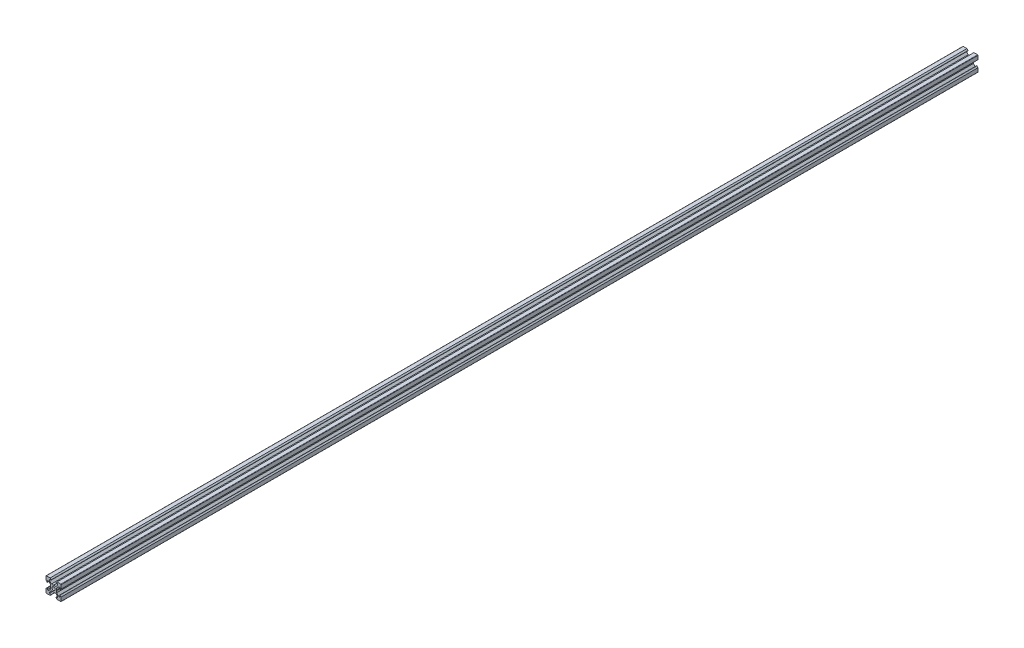
from build123d import *

# Parameters (mm, degrees)
SKETCH1_R           = 2.1
BOSS_EXTRUDE1_DEPTH = 1210


with BuildPart() as part:
    # Sketch1 → Boss-Extrude1 (new body)
    with BuildSketch(Plane.XY):
        with BuildLine():
            Line((4.58, -10), (9.5, -10))
            ThreePointArc((9.5, -10), (9.853553391, -9.853553391), (10, -9.5))
            Line((10, -9.5), (10, -4.58))
            Line((10, -4.58), (8.545, -3.125))
            Line((8.545, -3.125), (8.2, -3.125))
            Line((8.2, -3.125), (8.2, -5.5))
            Line((8.2, -5.5), (6.560660172, -5.5))
            Line((6.560660172, -5.5), (3.9, -2.839339828))
            Line((3.9, -2.839339828), (3.9, -0.21))
            Line((3.9, -0.21), (3.69, 0))
            Line((3.69, 0), (3.9, 0.21))
            Line((3.9, 0.21), (3.9, 2.839339828))
            Line((3.9, 2.839339828), (6.560660172, 5.5))
            Line((6.560660172, 5.5), (8.2, 5.5))
            Line((8.2, 5.5), (8.2, 3.125))
            Line((8.2, 3.125), (8.545, 3.125))
            Line((8.545, 3.125), (10, 4.58))
            Line((10, 4.58), (10, 9.5))
            ThreePointArc((10, 9.5), (9.853553391, 9.853553391), (9.5, 10))
            Line((9.5, 10), (4.58, 10))
            Line((4.58, 10), (3.125, 8.545))
            Line((3.125, 8.545), (3.125, 8.2))
            Line((3.125, 8.2), (5.5, 8.2))
            Line((5.5, 8.2), (5.5, 6.560660172))
            Line((5.5, 6.560660172), (2.839339828, 3.9))
            Line((2.839339828, 3.9), (0.21, 3.9))
            Line((0.21, 3.9), (0, 3.69))
            Line((0, 3.69), (-0.21, 3.9))
            Line((-0.21, 3.9), (-2.839339828, 3.9))
            Line((-2.839339828, 3.9), (-5.5, 6.560660172))
            Line((-5.5, 6.560660172), (-5.5, 8.2))
            Line((-5.5, 8.2), (-3.125, 8.2))
            Line((-3.125, 8.2), (-3.125, 8.545))
            Line((-3.125, 8.545), (-4.58, 10))
            Line((-4.58, 10), (-9.5, 10))
            ThreePointArc((-9.5, 10), (-9.853553391, 9.853553391), (-10, 9.5))
            Line((-10, 9.5), (-10, 4.58))
            Line((-10, 4.58), (-8.545, 3.125))
            Line((-8.545, 3.125), (-8.2, 3.125))
            Line((-8.2, 3.125), (-8.2, 5.5))
            Line((-8.2, 5.5), (-6.560660172, 5.5))
            Line((-6.560660172, 5.5), (-3.9, 2.839339828))
            Line((-3.9, 2.839339828), (-3.9, 0.21))
            Line((-3.9, 0.21), (-3.69, 0))
            Line((-3.69, 0), (-3.9, -0.21))
            Line((-3.9, -0.21), (-3.9, -2.839339828))
            Line((-3.9, -2.839339828), (-6.560660172, -5.5))
            Line((-6.560660172, -5.5), (-8.2, -5.5))
            Line((-8.2, -5.5), (-8.2, -3.125))
            Line((-8.2, -3.125), (-8.545, -3.125))
            Line((-8.545, -3.125), (-10, -4.58))
            Line((-10, -4.58), (-10, -9.5))
            ThreePointArc((-10, -9.5), (-9.853553391, -9.853553391), (-9.5, -10))
            Line((-9.5, -10), (-4.58, -10))
            Line((-4.58, -10), (-3.125, -8.545))
            Line((-3.125, -8.545), (-3.125, -8.2))
            Line((-3.125, -8.2), (-5.5, -8.2))
            Line((-5.5, -8.2), (-5.5, -6.560660172))
            Line((-5.5, -6.560660172), (-2.839339828, -3.9))
            Line((-2.839339828, -3.9), (-0.21, -3.9))
            Line((-0.21, -3.9), (0, -3.69))
            Line((0, -3.69), (0.21, -3.9))
            Line((0.21, -3.9), (2.839339828, -3.9))
            Line((2.839339828, -3.9), (5.5, -6.560660172))
            Line((5.5, -6.560660172), (5.5, -8.2))
            Line((5.5, -8.2), (3.125, -8.2))
            Line((3.125, -8.2), (3.125, -8.545))
            Line((3.125, -8.545), (4.58, -10))
        make_face()
        Circle(SKETCH1_R, mode=Mode.SUBTRACT)
    extrude(amount=BOSS_EXTRUDE1_DEPTH)


solid = part.part
